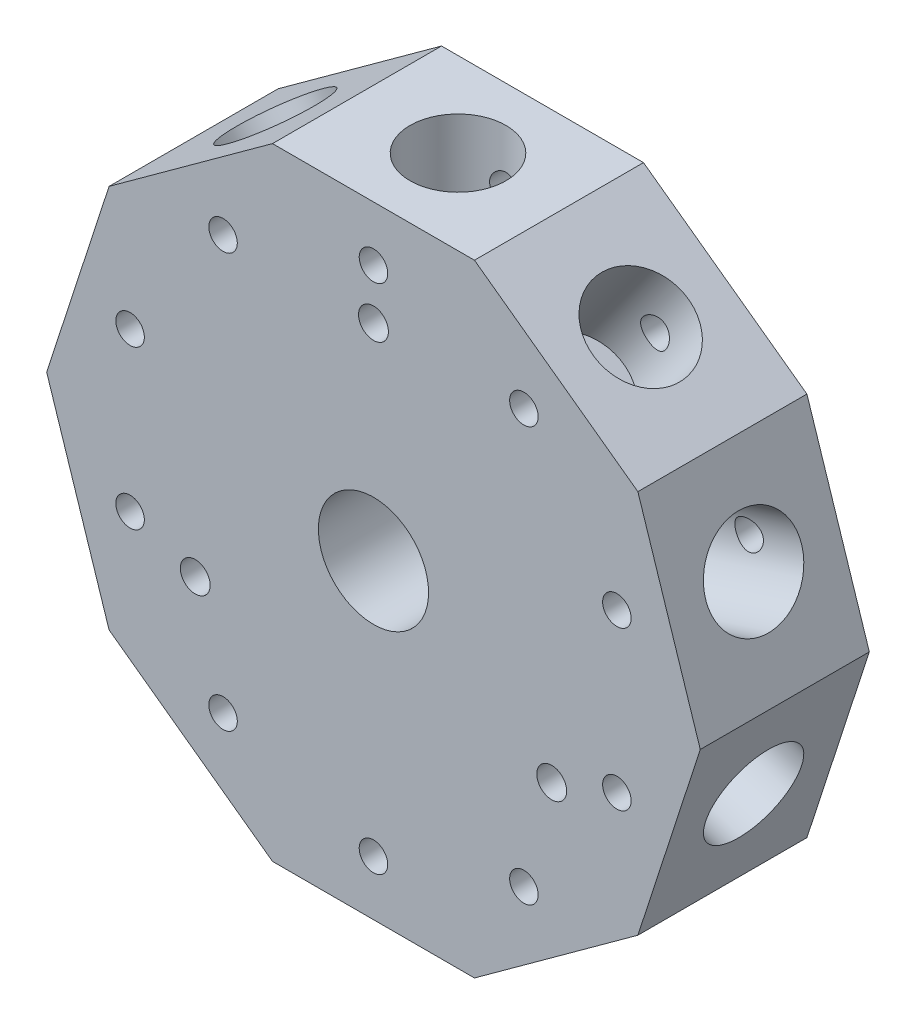
from build123d import *

# Parameters (mm, degrees)
BOSS_EXTRUDE1_DEPTH       = 19.558
SKETCH5_R                 = 5.5499
CUT_EXTRUDE3_DEPTH        = 12.7
SKETCH6_R                 = 5.5499
CUT_EXTRUDE4_DEPTH        = 12.7
SKETCH7_R                 = 5.5499
CUT_EXTRUDE5_DEPTH        = 12.7
SKETCH8_R                 = 5.5499
CUT_EXTRUDE6_DEPTH        = 12.7
SKETCH9_R                 = 5.5499
CUT_EXTRUDE7_DEPTH        = 12.7
SKETCH10_R                = 5.5499
CUT_EXTRUDE8_DEPTH        = 12.7
SKETCH11_R                = 5.5499
CUT_EXTRUDE9_DEPTH        = 12.7
SKETCH12_R                = 5.5499
CUT_EXTRUDE10_DEPTH       = 12.7
SKETCH13_R                = 5.5499
CUT_EXTRUDE11_DEPTH       = 12.7
SKETCH14_R                = 5.5499
CUT_EXTRUDE12_DEPTH       = 12.7
SKETCH16_R                = 9.525
BOSS_EXTRUDE2_DEPTH       = 12.7
SKETCH17_R                = 6.3754
CUT_EXTRUDE13_DEPTH       = 15.24
SKETCH18_R                = 1.63195
CUT_EXTRUDE14_DEPTH       = 20.558
SKETCH19_R                = 1.905
CUT_EXTRUDE15_DEPTH       = 36.959654548
CUT_EXTRUDE15_DEPTH_BACK  = 36.959654548
SKETCH21_R                = 6.3754
CUT_EXTRUDE16_DEPTH       = 18.0180001
SKETCH23_R                = 9.525
CUT_EXTRUDE17_DEPTH       = 12.7
F_8_32_TAPPED_HOLE1_D     = 3.4544
M4X0_7_TAPPED_HOLE1_D     = 3.3
M4X0_7_TAPPED_HOLE1_DEPTH = 19.558


with BuildPart() as part:
    # Sketch1 → Boss-Extrude1 (new body)
    with BuildSketch(Plane.XY):
        Polygon((30.589109125, 22.224288673), (11.684, 35.959654448), (-11.684, 35.959654448), (-30.589109125, 22.224288673), (-37.810218249, 0), (-30.589109125, -22.224288673), (-11.684, -35.959654448), (11.684, -35.959654448), (30.589109125, -22.224288673), (37.810218249, 0), align=None)
    extrude(amount=-BOSS_EXTRUDE1_DEPTH)

    # Sketch5 → Cut-Extrude3 (cut)
    with BuildSketch(Plane(origin=(0, 35.959654448, 0), x_dir=(1, 0, 0), z_dir=(0, 1, 0))):
        with Locations((0, 9.779)):
            Circle(SKETCH5_R)
    extrude(amount=-CUT_EXTRUDE3_DEPTH, mode=Mode.SUBTRACT)

    # Sketch6 → Cut-Extrude4 (cut)
    with BuildSketch(Plane(origin=(21.136554562, 29.091971561, 0), x_dir=(0.809016994, -0.587785252, 0), z_dir=(0.587785252, 0.809016994, 0))):
        with Locations((0, 9.779)):
            Circle(SKETCH6_R)
    extrude(amount=-CUT_EXTRUDE4_DEPTH, mode=Mode.SUBTRACT)

    # Sketch7 → Cut-Extrude5 (cut)
    with BuildSketch(Plane(origin=(34.199663687, 11.112144336, 0), x_dir=(0, 0, -1), z_dir=(0.951056516, 0.309016994, 0))):
        with Locations((9.779, 0)):
            Circle(SKETCH7_R)
    extrude(amount=-CUT_EXTRUDE5_DEPTH, mode=Mode.SUBTRACT)

    # Sketch8 → Cut-Extrude6 (cut)
    with BuildSketch(Plane(origin=(34.199663687, -11.112144336, 0), x_dir=(0, 0, -1), z_dir=(0.951056516, -0.309016994, 0))):
        with Locations((9.779, 0)):
            Circle(SKETCH8_R)
    extrude(amount=-CUT_EXTRUDE6_DEPTH, mode=Mode.SUBTRACT)

    # Sketch9 → Cut-Extrude7 (cut)
    with BuildSketch(Plane(origin=(21.136554562, -29.091971561, 0), x_dir=(0.809016994, 0.587785252, 0), z_dir=(0.587785252, -0.809016994, 0))):
        with Locations((0, -9.779)):
            Circle(SKETCH9_R)
    extrude(amount=-CUT_EXTRUDE7_DEPTH, mode=Mode.SUBTRACT)

    # Sketch10 → Cut-Extrude8 (cut)
    with BuildSketch(Plane.XZ.offset(35.959654448)):
        with Locations((0, -9.779)):
            Circle(SKETCH10_R)
    extrude(amount=-CUT_EXTRUDE8_DEPTH, mode=Mode.SUBTRACT)

    # Sketch11 → Cut-Extrude9 (cut)
    with BuildSketch(Plane(origin=(-21.136554562, -29.091971561, 0), x_dir=(0.809016994, -0.587785252, 0), z_dir=(-0.587785252, -0.809016994, 0))):
        with Locations((0, -9.779)):
            Circle(SKETCH11_R)
    extrude(amount=-CUT_EXTRUDE9_DEPTH, mode=Mode.SUBTRACT)

    # Sketch12 → Cut-Extrude10 (cut)
    with BuildSketch(Plane(origin=(-34.199663687, -11.112144336, 0), x_dir=(0, 0, 1), z_dir=(-0.951056516, -0.309016994, 0))):
        with Locations((-9.779, 0)):
            Circle(SKETCH12_R)
    extrude(amount=-CUT_EXTRUDE10_DEPTH, mode=Mode.SUBTRACT)

    # Sketch13 → Cut-Extrude11 (cut)
    with BuildSketch(Plane(origin=(-34.199663687, 11.112144336, 0), x_dir=(0, 0, 1), z_dir=(-0.951056516, 0.309016994, 0))):
        with Locations((-9.779, 0)):
            Circle(SKETCH13_R)
    extrude(amount=-CUT_EXTRUDE11_DEPTH, mode=Mode.SUBTRACT)

    # Sketch14 → Cut-Extrude12 (cut)
    with BuildSketch(Plane(origin=(-21.136554562, 29.091971561, 0), x_dir=(0.809016994, 0.587785252, 0), z_dir=(-0.587785252, 0.809016994, 0))):
        with Locations((0, 9.779)):
            Circle(SKETCH14_R)
    extrude(amount=-CUT_EXTRUDE12_DEPTH, mode=Mode.SUBTRACT)

    # Sketch16 → Boss-Extrude2 (add)
    with BuildSketch(Plane.XY):
        Circle(SKETCH16_R)
    extrude(amount=BOSS_EXTRUDE2_DEPTH)

    # Sketch17 → Cut-Extrude13 (cut)
    with BuildSketch(Plane.XY.offset(12.7)):
        Circle(SKETCH17_R)
    extrude(amount=-CUT_EXTRUDE13_DEPTH, mode=Mode.SUBTRACT)

    # Sketch18 → Cut-Extrude14 (cut, through all)
    with BuildSketch(Plane.XY):
        with Locations((0, 29.609654448)):
            Circle(SKETCH18_R)
        with Locations((17.40411821, 23.954713646)):
            Circle(SKETCH18_R)
        with Locations((28.160454808, 9.149886422)):
            Circle(SKETCH18_R)
        with Locations((28.160454808, -9.149886422)):
            Circle(SKETCH18_R)
        with Locations((17.40411821, -23.954713646)):
            Circle(SKETCH18_R)
        with Locations((0, -29.609654448)):
            Circle(SKETCH18_R)
        with Locations((-17.40411821, -23.954713646)):
            Circle(SKETCH18_R)
        with Locations((-28.160454808, -9.149886422)):
            Circle(SKETCH18_R)
        with Locations((-28.160454808, 9.149886422)):
            Circle(SKETCH18_R)
        with Locations((-17.40411821, 23.954713646)):
            Circle(SKETCH18_R)
    extrude(amount=-CUT_EXTRUDE14_DEPTH, mode=Mode.SUBTRACT)

    # Sketch19 → Cut-Extrude15 (cut, two sides)
    with BuildSketch(Plane(origin=(0, 0, 0), x_dir=(1, 0, 0), z_dir=(0, 1, 0))) as cut_extrude15_sk:
        with Locations((0, -6.35)):
            Circle(SKETCH19_R)
    extrude(amount=CUT_EXTRUDE15_DEPTH, mode=Mode.SUBTRACT)
    extrude(cut_extrude15_sk.sketch, amount=-CUT_EXTRUDE15_DEPTH_BACK, mode=Mode.SUBTRACT)

    # Sketch21 → Cut-Extrude16 (cut, through all)
    with BuildSketch(Plane.XY.offset(-2.54)):
        Circle(SKETCH21_R)
    extrude(amount=-CUT_EXTRUDE16_DEPTH, mode=Mode.SUBTRACT)

    # Sketch23 → Cut-Extrude17 (cut)
    with BuildSketch(Plane.XY.offset(12.7)):
        Circle(SKETCH23_R)
    extrude(amount=-CUT_EXTRUDE17_DEPTH, mode=Mode.SUBTRACT)

    # #8-32 Tapped Hole1 (through all)
    with Locations(Plane.XY):
        with Locations((0, 23.8125), (20.622229928, -11.90625), (-20.622229928, -11.90625)):
            Hole(F_8_32_TAPPED_HOLE1_D / 2)

    # M4x0.7 Tapped Hole1
    with Locations(Plane.XY):
        with Locations((-17.40411821, 23.954713646), (-28.160454808, 9.149886422), (-28.160454808, -9.149886422), (-17.40411821, -23.954713646), (0, -29.609654448), (17.40411821, -23.954713646), (28.160454808, -9.149886422), (28.160454808, 9.149886422), (17.40411821, 23.954713646), (0, 29.609654448)):
            Hole(M4X0_7_TAPPED_HOLE1_D / 2, depth=M4X0_7_TAPPED_HOLE1_DEPTH)


solid = part.part
